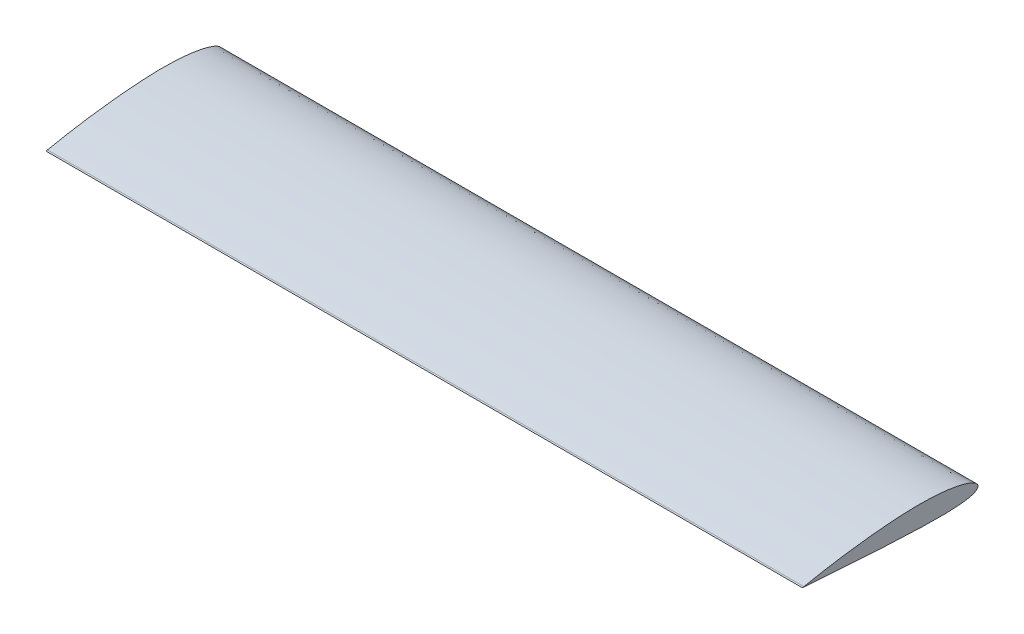
from build123d import *

# Parameters (mm, degrees)
BOSS_EXTRUDE1_DEPTH = 1000


with BuildPart() as part:
    # Sketch4 → Boss-Extrude1 (new body, symmetric)
    with BuildSketch(Plane(origin=(0, 0, 0), x_dir=(0, 0, -1), z_dir=(1, 0, 0))):
        with BuildLine():
            Line((-460.03864, 0.57822), (-464.061002051, -0.259696924))
            Line((-464.061002051, -0.259696924), (-459.96136, -0.57822))
            add(Edge.make_bspline(
                [(-460.03864, 0.57822), (-459.804502952, 0.626994176), (-458.869283275, 0.821814131), (-456.770234003, 1.257488102), (-453.285301887, 1.974574051), (-448.434337026, 2.958941866), (-442.24599338, 4.194300673), (-434.75600228, 5.65763481), (-426.008341953, 7.323698371), (-416.054516582, 9.165416058), (-404.953123159, 11.151436099), (-392.770491909, 13.250829114), (-379.579206865, 15.431819212), (-365.458406813, 17.660843075), (-350.493218457, 19.90510515), (-334.774661072, 22.132373857), (-318.39829014, 24.309261206), (-301.464229531, 26.403557407), (-284.076486433, 28.38530685), (-266.342124235, 30.219827139), (-248.371165836, 31.880450429), (-230.275245946, 33.333659787), (-212.167609701, 34.555703307), (-194.14113377, 35.517678069), (-176.282304318, 36.207087085), (-158.701138059, 36.49713223), (-141.534269902, 36.385525064), (-124.921332834, 35.869692938), (-108.972143147, 34.95588337), (-93.792202098, 33.657684246), (-79.481103225, 31.997931357), (-66.132373485, 30.004483538), (-53.831599057, 27.712613416), (-42.65660762, 25.161183198), (-32.674860802, 22.395925834), (-23.945432651, 19.459548047), (-16.514472954, 16.398694071), (-10.416631234, 13.254106027), (-5.667111603, 10.056997637), (-2.268617609, 6.814040686), (-0.223340444, 3.460752783), (0.262262833, -0.026267921), (-0.902718938, -3.345117856), (-3.550148024, -6.230464989), (-7.478215909, -8.75690384), (-12.685639332, -11.006524327), (-19.163705269, -12.990809583), (-26.885292194, -14.711996286), (-35.808181999, -16.165707734), (-45.879865713, -17.350638105), (-57.039926144, -18.268690236), (-69.221803068, -18.927613299), (-82.353779507, -19.33791586), (-96.359307858, -19.516691241), (-111.157748759, -19.483345151), (-126.664381158, -19.264335817), (-142.790888208, -18.886345318), (-159.445496034, -18.382180637), (-176.559622724, -17.778407046), (-194.055351039, -17.117172917), (-211.825044665, -16.31754337), (-229.735221004, -15.419542985), (-247.656722582, -14.44274166), (-265.480797864, -13.414893843), (-283.098611655, -12.354687974), (-300.402068621, -11.282823043), (-317.284462612, -10.213031314), (-333.641469008, -9.160369319), (-349.371410608, -8.136112525), (-364.376091402, -7.148929444), (-378.561285931, -6.207894269), (-391.83775108, -5.318012265), (-404.121471111, -4.488169814), (-415.334397245, -3.722501591), (-425.404870433, -3.028324144), (-434.26842329, -2.410636148), (-441.868019552, -1.8753416), (-448.15451643, -1.429044859), (-453.087022947, -1.075343915), (-456.633473905, -0.820097256), (-458.770577001, -0.664750447), (-459.722926634, -0.595546201), (-459.96136, -0.57822)],
                knots=[0, 0, 0, 0, 0.000764172, 0.003052354, 0.006849806, 0.012132473, 0.018867992, 0.027012839, 0.036516812, 0.047320748, 0.059356871, 0.072550805, 0.086820052, 0.102077398, 0.118227703, 0.135170889, 0.152802297, 0.171012918, 0.18968989, 0.20871821, 0.227978895, 0.247353901, 0.266722825, 0.285966043, 0.30503218, 0.323824437, 0.342143817, 0.359879711, 0.376925818, 0.393181853, 0.408552719, 0.422951453, 0.436298149, 0.448522824, 0.459565428, 0.469379445, 0.477933616, 0.485220338, 0.491267538, 0.496167824, 0.50013339, 0.503587222, 0.507040597, 0.511000028, 0.515876125, 0.521872239, 0.529071215, 0.537494991, 0.547131181, 0.557945451, 0.569889642, 0.582904388, 0.596921672, 0.611866369, 0.627656322, 0.64420424, 0.661417059, 0.679197208, 0.697442956, 0.716133923, 0.735139063, 0.75427754, 0.773432072, 0.792486537, 0.811323416, 0.82982615, 0.847880344, 0.865374073, 0.882198025, 0.89824695, 0.913420544, 0.927622056, 0.940762976, 0.952758838, 0.963532927, 0.973016418, 0.981148268, 0.987875252, 0.99315353, 0.996949037, 0.999236151, 1, 1, 1, 1], degree=3))
        make_face()
    extrude(amount=BOSS_EXTRUDE1_DEPTH, both=True)


solid = part.part
